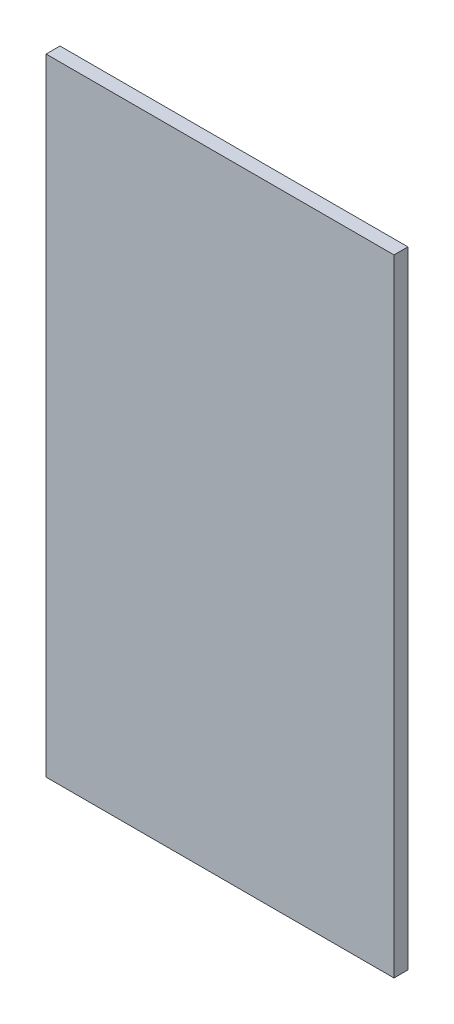
from build123d import *

# Parameters (mm, degrees)
SKETCH1_W           = 500
SKETCH1_H           = 900
BOSS_EXTRUDE1_DEPTH = 20


with BuildPart() as part:
    # Sketch1 → Boss-Extrude1 (new body)
    with BuildSketch(Plane.XY):
        Rectangle(SKETCH1_W, SKETCH1_H)
    extrude(amount=BOSS_EXTRUDE1_DEPTH)


solid = part.part
